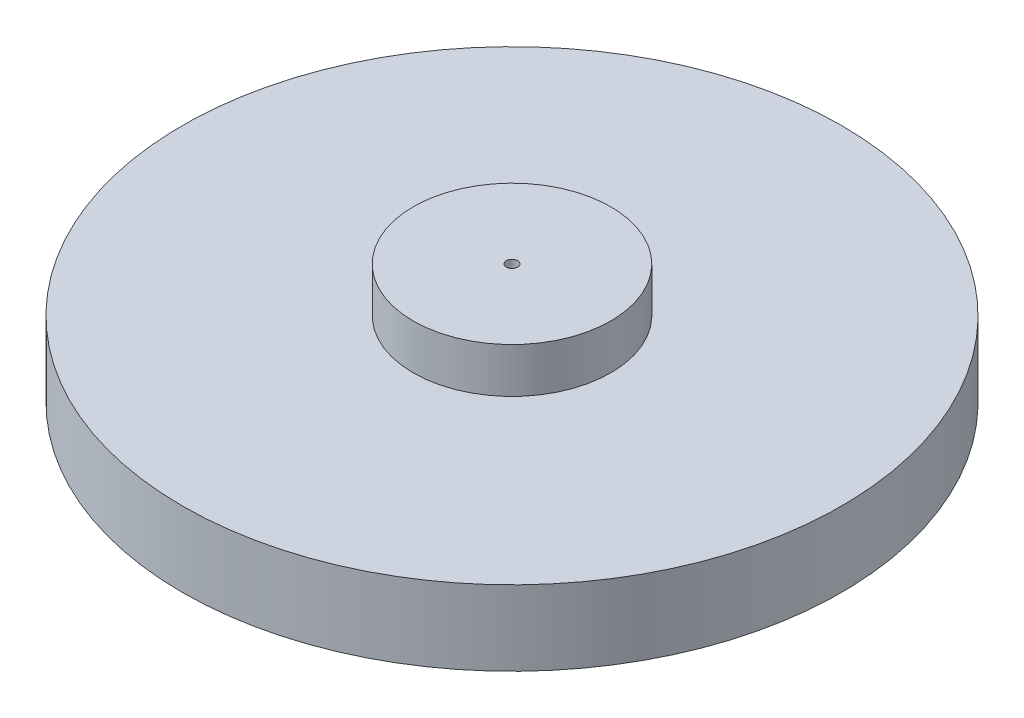
from build123d import *

# Parameters (mm, degrees)
SKETCH1_R           = 69.85
BOSS_EXTRUDE1_DEPTH = 15.875
SKETCH2_R           = 20.955
BOSS_EXTRUDE2_DEPTH = 9.525
SKETCH13_R          = 41.275
SKETCH13_R_2        = 33.02
SKETCH13_R_3        = 25.4
SKETCH13_R_4        = 14.2875
SKETCH13_R_5        = 7.62
CUT_EXTRUDE10_DEPTH = 6.35
SKETCH14_R          = 1.190625
CUT_EXTRUDE11_DEPTH = 20.05


with BuildPart() as part:
    # Sketch1 → Boss-Extrude1 (new body)
    with BuildSketch(Plane(origin=(0, 0, 0), x_dir=(1, 0, 0), z_dir=(0, 1, 0))):
        Circle(SKETCH1_R)
    extrude(amount=BOSS_EXTRUDE1_DEPTH)

    # Sketch2 → Boss-Extrude2 (add)
    with BuildSketch(Plane(origin=(0, 15.875, 0), x_dir=(1, 0, 0), z_dir=(0, 1, 0))):
        Circle(SKETCH2_R)
    extrude(amount=BOSS_EXTRUDE2_DEPTH)

    # Sketch13 → Cut-Extrude10 (cut)
    with BuildSketch(Plane.XZ):
        Circle(SKETCH13_R)
        Circle(SKETCH13_R_2, mode=Mode.SUBTRACT)
        Circle(SKETCH13_R_3)
        Circle(SKETCH13_R_4, mode=Mode.SUBTRACT)
        Circle(SKETCH13_R_5)
    extrude(amount=-CUT_EXTRUDE10_DEPTH, mode=Mode.SUBTRACT)

    # Sketch14 → Cut-Extrude11 (cut, through all)
    with BuildSketch(Plane.XZ.offset(-6.35)):
        Circle(SKETCH14_R)
    extrude(amount=-CUT_EXTRUDE11_DEPTH, mode=Mode.SUBTRACT)


solid = part.part
